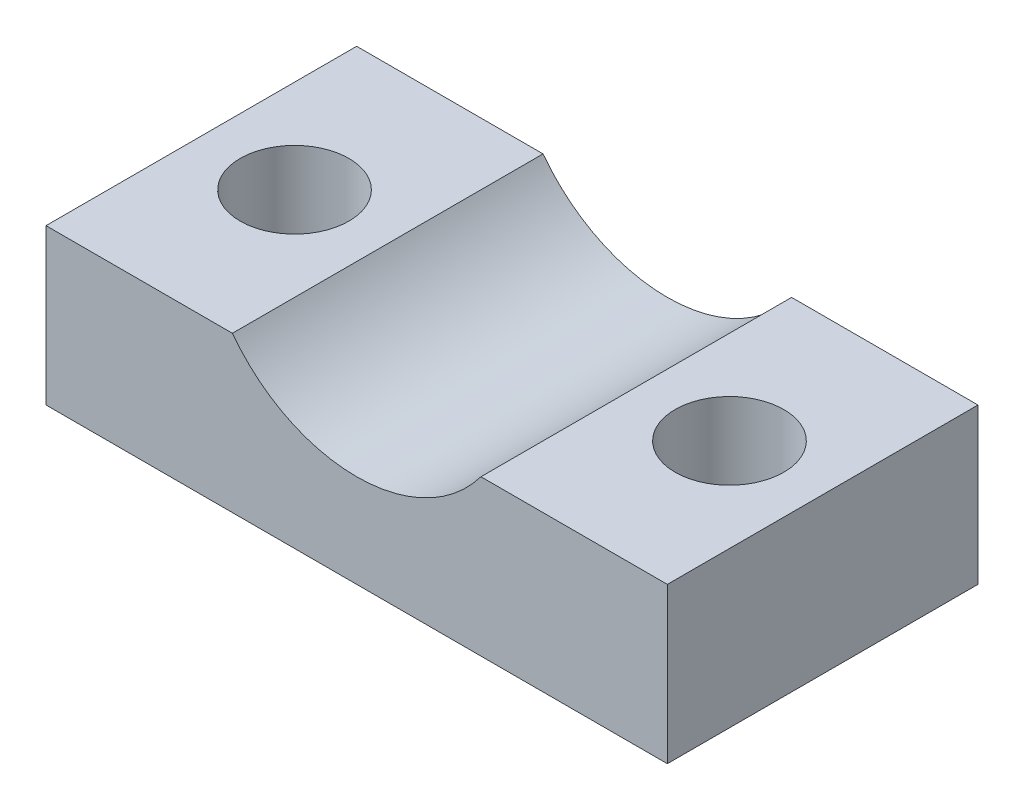
from build123d import *

# Parameters (mm, degrees)
AUFSATZ_LINEAR_AUSTRAGEN1_DEPTH = 10
SKIZZE2_R                       = 1.75
SCHNITT_LINEAR_AUSTRAGEN1_DEPTH = 6


with BuildPart() as part:
    # Skizze1 → Aufsatz-Linear austragen1 (new body)
    with BuildSketch(Plane.XY):
        with BuildLine():
            Line((0, 0), (20, 0))
            Line((20, 0), (20, 5))
            Line((20, 5), (14, 5))
            ThreePointArc((14, 5), (10, 3), (6, 5))
            Line((6, 5), (0, 5))
            Line((0, 5), (0, 0))
        make_face()
    extrude(amount=AUFSATZ_LINEAR_AUSTRAGEN1_DEPTH)

    # Skizze2 → Schnitt-Linear austragen1 (cut, through all)
    with BuildSketch(Plane(origin=(0, 5, 0), x_dir=(1, 0, 0), z_dir=(0, 1, 0))):
        with Locations((3, -5)):
            Circle(SKIZZE2_R)
        with Locations((17, -5)):
            Circle(SKIZZE2_R)
    extrude(amount=-SCHNITT_LINEAR_AUSTRAGEN1_DEPTH, mode=Mode.SUBTRACT)


solid = part.part
